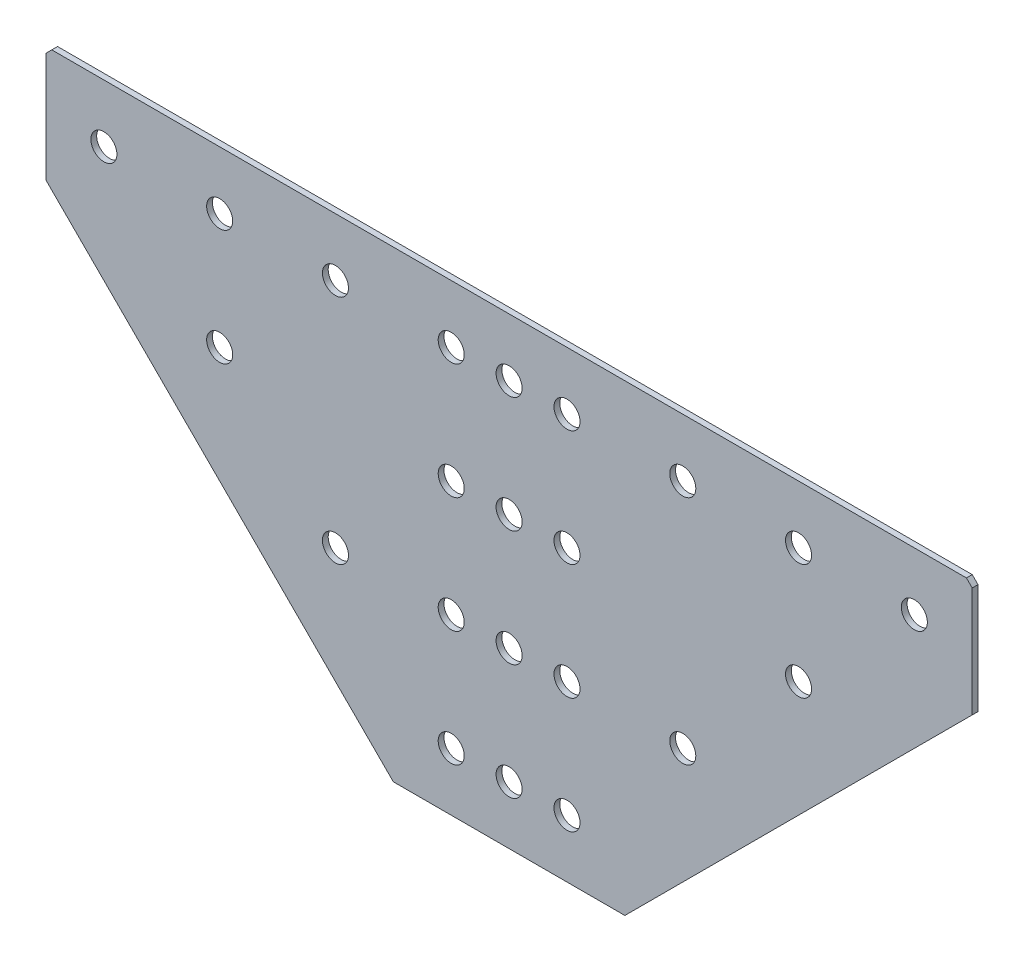
from build123d import *

# Parameters (mm, degrees)
EXTRUDE_1_DEPTH   = 2
CHAMFER_1_SIZE    = 2
HOLE_WIZARD_M81_D = 9


with BuildPart() as part:
    # Эскиз1 → Бобышка-Вытянуть1 (new body)
    with BuildSketch(Plane.XY):
        Polygon((160, -40), (40, -160), (-40, -160), (-160, -40), (-160, 0), (160, 0), align=None)
    extrude(amount=EXTRUDE_1_DEPTH)

    # Фаска1
    chamfer_1_edges = [part.edges().sort_by_distance(p)[0] for p in [
        (160, 0, 1),
        (-160, 0, 1),
    ]]
    chamfer(chamfer_1_edges, length=CHAMFER_1_SIZE)

    # Отверстие с зазором M81 (through all)
    with Locations(Plane.XY.offset(2)):
        with Locations((60, -100), (0, -20), (20, -20), (-20, -20), (-20, -60), (-20, -100), (-20, -140), (0, -60), (0, -100), (0, -140), (20, -60), (20, -100), (20, -140), (-60, -20), (-100, -20), (-140, -20), (60, -20), (100, -20), (140, -20), (-100, -60), (100, -60), (-60, -100)):
            Hole(HOLE_WIZARD_M81_D / 2)


solid = part.part
